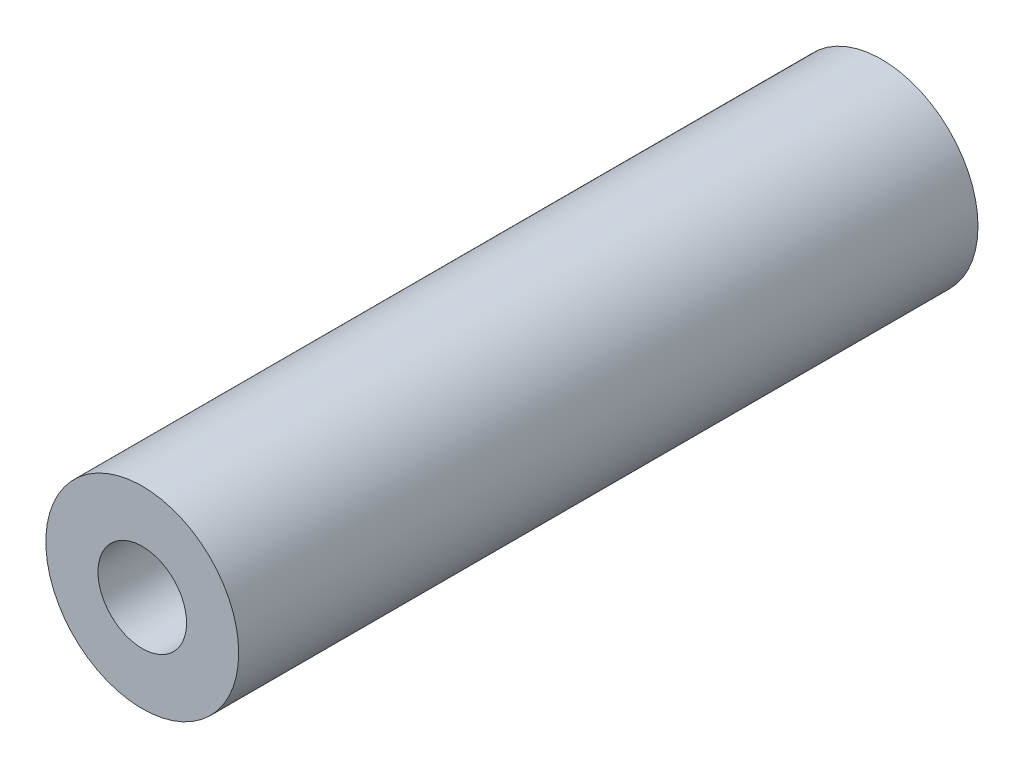
from build123d import *

# Parameters (mm, degrees)
SKETCH1_R               = 38.1
BOSS_EXTRUDE1_DEPTH     = 292.1
SKETCH3_R               = 17.5
CUT_EXTRUDE1_DEPTH      = 1
CUT_EXTRUDE1_DEPTH_BACK = 293.1


with BuildPart() as part:
    # Sketch1 → Boss-Extrude1 (new body)
    with BuildSketch(Plane.XY):
        Circle(SKETCH1_R)
    extrude(amount=BOSS_EXTRUDE1_DEPTH)

    # Sketch3 → Cut-Extrude1 (cut, two sides)
    with BuildSketch(Plane.XY.offset(292.1)) as cut_extrude1_sk:
        Circle(SKETCH3_R)
    extrude(amount=CUT_EXTRUDE1_DEPTH, mode=Mode.SUBTRACT)
    extrude(cut_extrude1_sk.sketch, amount=-CUT_EXTRUDE1_DEPTH_BACK, mode=Mode.SUBTRACT)


solid = part.part
